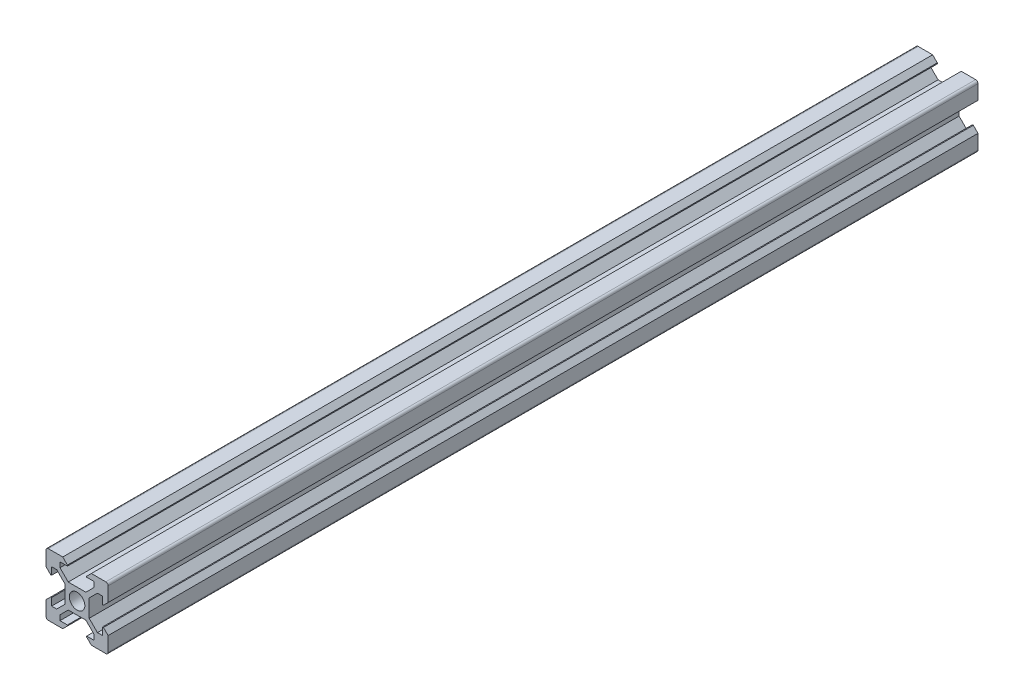
from build123d import *

# Parameters (mm, degrees)
CROQUIS1_R              = 2.5
SALIENTE_EXTRUIR1_DEPTH = 280


with BuildPart() as part:
    # Croquis1 → Saliente-Extruir1 (new body)
    with BuildSketch(Plane.XY):
        with BuildLine():
            Line((-4.6, 10), (-3.1, 8.5))
            Line((-3.1, 8.5), (-3.1, 8.2))
            Line((-3.1, 8.2), (-5.5, 8.2))
            Line((-5.5, 8.2), (-5.5, 6.560660172))
            Line((-5.5, 6.560660172), (-2.84, 3.900660172))
            Line((-2.84, 3.900660172), (0, 3.900660172))
            Line((0, 3.900660172), (2.84, 3.900660172))
            Line((2.84, 3.900660172), (5.5, 6.560660172))
            Line((5.5, 6.560660172), (5.5, 8.2))
            Line((5.5, 8.2), (3.1, 8.2))
            Line((3.1, 8.2), (3.1, 8.5))
            Line((3.1, 8.5), (4.6, 10))
            Line((4.6, 10), (9.25, 10))
            ThreePointArc((9.25, 10), (9.780330086, 9.780330086), (10, 9.25))
            Line((10, 9.25), (10, 4.6))
            Line((10, 4.6), (8.5, 3.1))
            Line((8.5, 3.1), (8.2, 3.1))
            Line((8.2, 3.1), (8.2, 5.5))
            Line((8.2, 5.5), (6.560660172, 5.5))
            Line((6.560660172, 5.5), (3.900660172, 2.84))
            Line((3.900660172, 2.84), (3.900660172, 0))
            Line((3.900660172, 0), (3.900660172, -2.84))
            Line((3.900660172, -2.84), (6.560660172, -5.5))
            Line((6.560660172, -5.5), (8.2, -5.5))
            Line((8.2, -5.5), (8.2, -3.1))
            Line((8.2, -3.1), (8.5, -3.1))
            Line((8.5, -3.1), (10, -4.6))
            Line((10, -4.6), (10, -9.25))
            ThreePointArc((10, -9.25), (9.780330086, -9.780330086), (9.25, -10))
            Line((9.25, -10), (4.6, -10))
            Line((4.6, -10), (3.1, -8.5))
            Line((3.1, -8.5), (3.1, -8.2))
            Line((3.1, -8.2), (5.5, -8.2))
            Line((5.5, -8.2), (5.5, -6.560660172))
            Line((5.5, -6.560660172), (2.84, -3.900660172))
            Line((2.84, -3.900660172), (0, -3.900660172))
            Line((0, -3.900660172), (-2.84, -3.900660172))
            Line((-2.84, -3.900660172), (-5.5, -6.560660172))
            Line((-5.5, -6.560660172), (-5.5, -8.2))
            Line((-5.5, -8.2), (-3.1, -8.2))
            Line((-3.1, -8.2), (-3.1, -8.5))
            Line((-3.1, -8.5), (-4.6, -10))
            Line((-4.6, -10), (-9.25, -10))
            ThreePointArc((-9.25, -10), (-9.780330086, -9.780330086), (-10, -9.25))
            Line((-10, -9.25), (-10, -4.6))
            Line((-10, -4.6), (-8.5, -3.1))
            Line((-8.5, -3.1), (-8.2, -3.1))
            Line((-8.2, -3.1), (-8.2, -5.5))
            Line((-8.2, -5.5), (-6.560660172, -5.5))
            Line((-6.560660172, -5.5), (-3.900660172, -2.84))
            Line((-3.900660172, -2.84), (-3.900660172, 0))
            Line((-3.900660172, 0), (-3.900660172, 2.84))
            Line((-3.900660172, 2.84), (-6.560660172, 5.5))
            Line((-6.560660172, 5.5), (-8.2, 5.5))
            Line((-8.2, 5.5), (-8.2, 3.1))
            Line((-8.2, 3.1), (-8.5, 3.1))
            Line((-8.5, 3.1), (-10, 4.6))
            Line((-10, 4.6), (-10, 9.25))
            ThreePointArc((-10, 9.25), (-9.780330086, 9.780330086), (-9.25, 10))
            Line((-9.25, 10), (-4.6, 10))
        make_face()
        Circle(CROQUIS1_R, mode=Mode.SUBTRACT)
    extrude(amount=SALIENTE_EXTRUIR1_DEPTH)


solid = part.part
